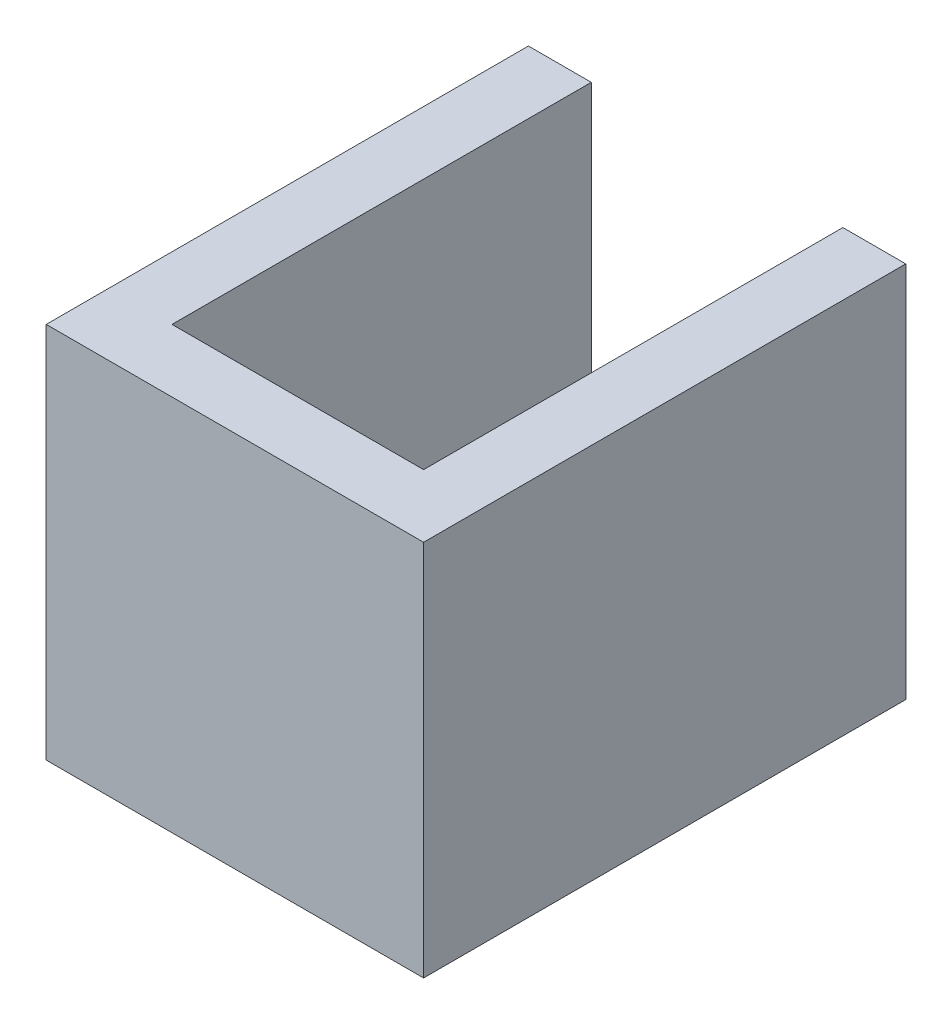
from build123d import *

# Parameters (mm, degrees)
BOSS_EXTRUDE1_DEPTH = 18


with BuildPart() as part:
    # Sketch1 → Boss-Extrude1 (new body)
    with BuildSketch(Plane(origin=(0, 0, 0), x_dir=(1, 0, 0), z_dir=(0, 1, 0))):
        Polygon((0, 23), (0, 0), (18, 0), (18, 23), (15, 23), (15, 3), (3, 3), (3, 23), align=None)
    extrude(amount=BOSS_EXTRUDE1_DEPTH)


solid = part.part
